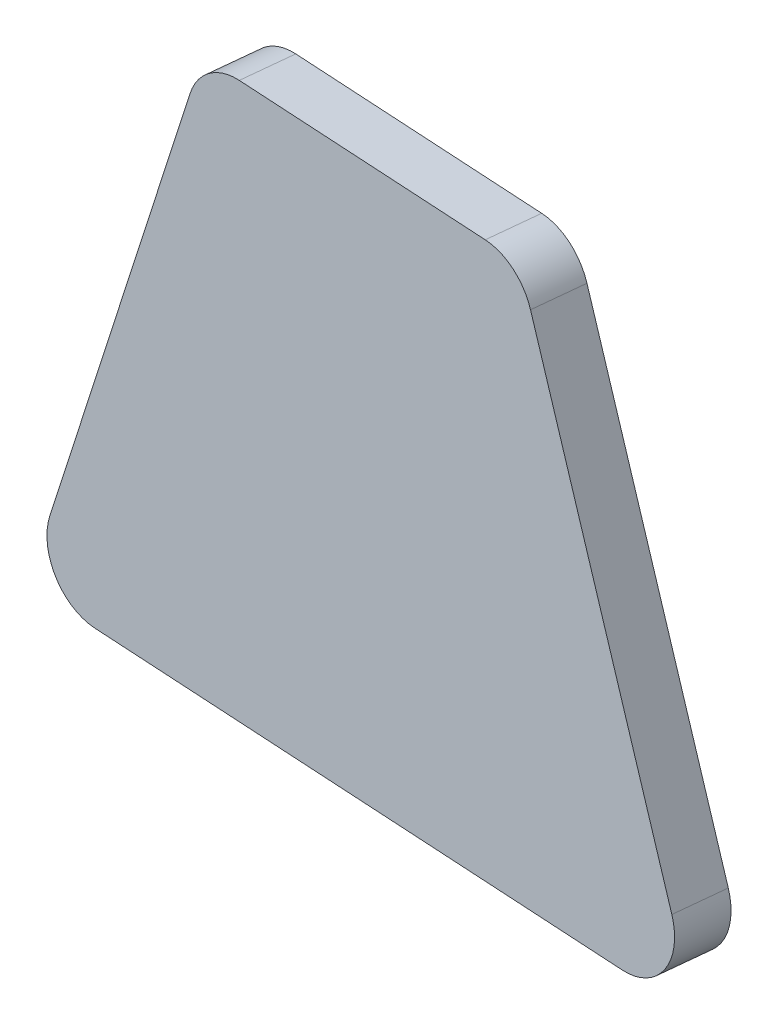
from build123d import *

# Parameters (mm, degrees)
BOSS_EXTRUDE1_DEPTH = 2.54
FILLET1_R           = 2.54


with BuildPart() as part:
    # Sketch1 → Boss-Extrude1 (new body)
    with BuildSketch(Plane(origin=(-8.073375318, 5.240605229, 134.378875143), x_dir=(0.998202842, 0.00233525, 0.059880156), z_dir=(-0.059925675, 0.038899072, 0.997444623))):
        Polygon((16.485952237, 500.26984873), (26.498547321, 474.86984873), (-7.418569241, 474.86984873), (0.410574683, 500.26984873), align=None)
    extrude(amount=BOSS_EXTRUDE1_DEPTH)

    # Fillet1
    fillet1_edges = [part.edges().sort_by_distance(p)[0] for p in [
        (8.306843448, 505.218357591, 117.137742749),
        (18.301444315, 479.861032939, 118.727113786),
        (-15.554717825, 479.781827994, 116.696151541),
        (-7.73964411, 505.180817566, 116.175146627),
    ]]
    fillet(fillet1_edges, radius=FILLET1_R)


solid = part.part
